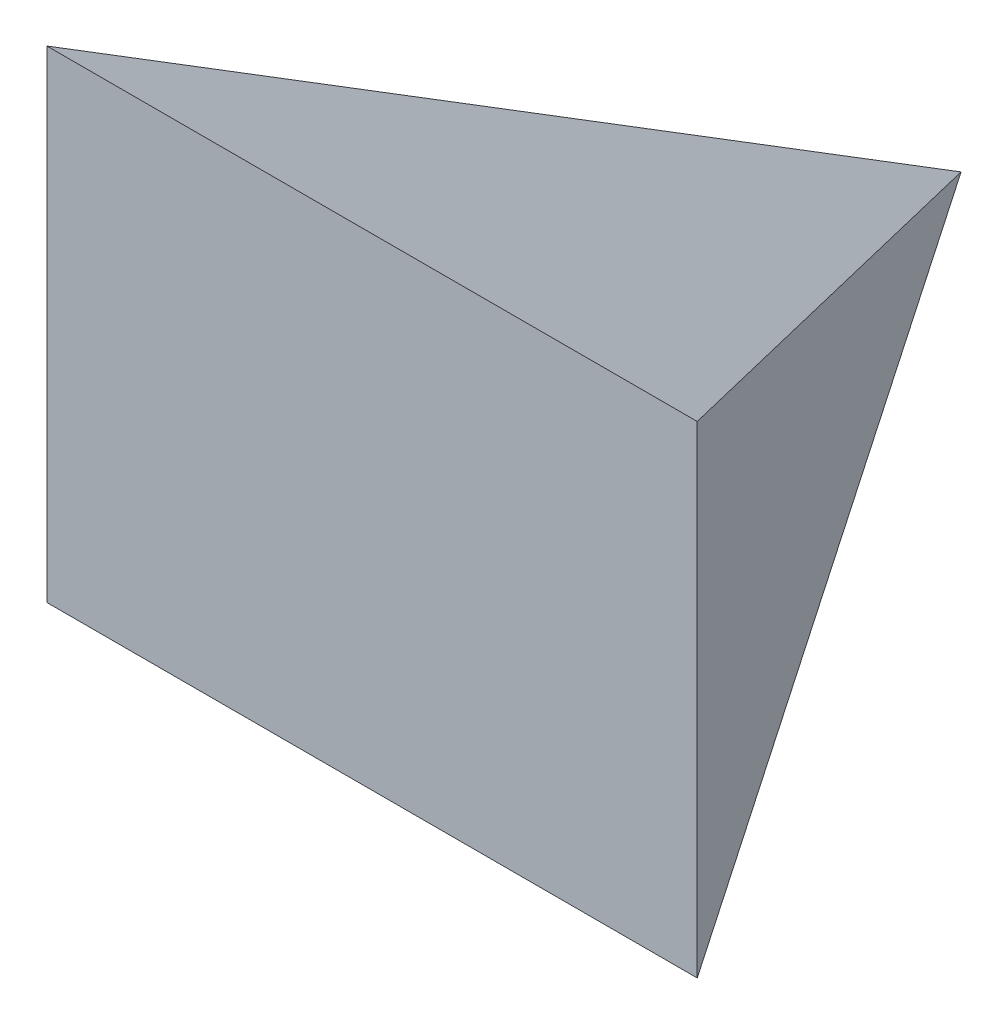
from build123d import *

# Parameters (mm, degrees)
BOSS_EXTRUDE1_DEPTH     = 250
SKETCH2_OUTSIDE_W       = 404.412
SKETCH2_OUTSIDE_H       = 354.412
CUT_EXTRUDE1_DEPTH      = 166.60889734
CUT_EXTRUDE1_DEPTH_BACK = 166.60889734


with BuildPart() as part:
    # Sketch1 → Boss-Extrude1 (new body)
    with BuildSketch(Plane(origin=(0, 0, 0), x_dir=(1, 0, 0), z_dir=(0, 1, 0))):
        Polygon((0, 0), (-165.60889734, -300), (165.60889734, -300), align=None)
    extrude(amount=BOSS_EXTRUDE1_DEPTH)

    # Sketch2 outside → Cut-Extrude1 (cut, two sides)
    with BuildSketch(Plane(origin=(0, 0, 0), x_dir=(0, 0, -1), z_dir=(1, 0, 0))) as cut_extrude1_sk:
        with Locations((-150, 125)):
            Rectangle(SKETCH2_OUTSIDE_W, SKETCH2_OUTSIDE_H)
        Polygon((0, 125), (-300, 247.733240428), (-300, 2.266759572), align=None, mode=Mode.SUBTRACT)
    extrude(amount=CUT_EXTRUDE1_DEPTH, mode=Mode.SUBTRACT)
    extrude(cut_extrude1_sk.sketch, amount=-CUT_EXTRUDE1_DEPTH_BACK, mode=Mode.SUBTRACT)


solid = part.part
